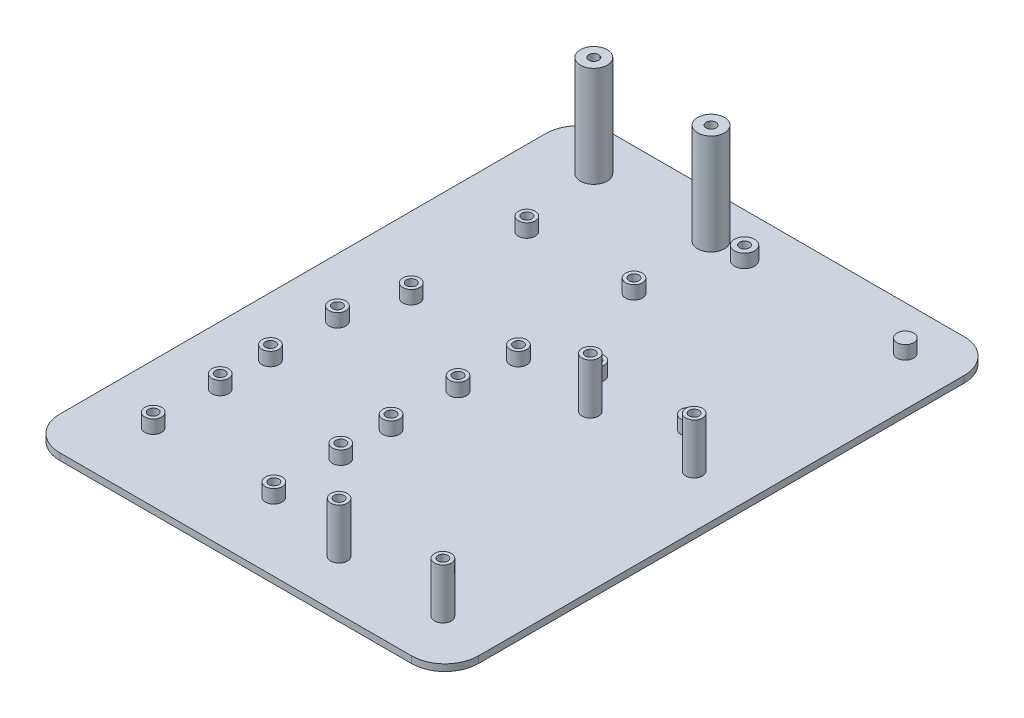
from build123d import *

# Parameters (mm, degrees)
SKETCH_1_R         = 2.5
EXTRUDE_1_DEPTH    = 4
SKETCH_1_R_2       = 3
EXTRUDE_1_2_DEPTH  = 4
EXTRUDE_1_3_DEPTH  = 4
EXTRUDE_1_4_DEPTH  = 4
EXTRUDE_1_5_DEPTH  = 4
EXTRUDE_1_6_DEPTH  = 4
EXTRUDE_1_7_DEPTH  = 4
EXTRUDE_1_8_DEPTH  = 4
EXTRUDE_1_9_DEPTH  = 4
EXTRUDE_1_10_DEPTH = 4
EXTRUDE_1_11_DEPTH = 4
EXTRUDE_1_12_DEPTH = 4
EXTRUDE_1_13_DEPTH = 4
EXTRUDE_1_14_DEPTH = 4
EXTRUDE_1_15_DEPTH = 4
EXTRUDE_1_16_DEPTH = 4
SKETCH_1_3_R       = 2.5
EXTRUDE_2_DEPTH    = 15
EXTRUDE_2_2_DEPTH  = 15
EXTRUDE_2_3_DEPTH  = 15
EXTRUDE_2_4_DEPTH  = 15
SKETCH_1_4_R       = 4
EXTRUDE_3_DEPTH    = 30
EXTRUDE_3_2_DEPTH  = 30
SKETCH_2_W         = 125
SKETCH_2_H         = 165
EXTRUDE_4_DEPTH    = 2
FILLET_1_R         = 10
SKETCH_9_W         = 1.475
SKETCH_9_H         = 30
MM_3_AT_2_COUNT    = 2
MM_3_AT_2_PITCH    = 56.007567425
MM_3_AT_3_COUNT    = 2
MM_3_AT_3_PITCH    = 72.159569674
MM_3_AT_4_COUNT    = 2
MM_3_AT_4_PITCH    = 52.22731905
MM_3_AT_5_COUNT    = 2
MM_3_AT_5_PITCH    = 37.325726715
MM_3_AT_6_COUNT    = 2
MM_3_AT_6_PITCH    = 17.717201651
MM_3_AT_7_COUNT    = 2
MM_3_AT_7_PITCH    = 34.5
MM_3_AT_8_COUNT    = 2
MM_3_AT_8_PITCH    = 59.709714453
MM_3_AT_9_COUNT    = 2
MM_3_AT_9_PITCH    = 66.635200908
MM_3_AT_10_COUNT   = 2
MM_3_AT_10_PITCH   = 71.695536821
MM_3_AT_11_COUNT   = 2
MM_3_AT_11_PITCH   = 75.871602066
MM_3_AT_12_COUNT   = 2
MM_3_AT_12_PITCH   = 86.987675624
MM_3_AT_13_COUNT   = 2
MM_3_AT_13_PITCH   = 116.476846242
MM_3_AT_14_COUNT   = 2
MM_3_AT_14_PITCH   = 95.586858976
MM_3_AT_15_COUNT   = 2
MM_3_AT_15_PITCH   = 78.355146818
MM_3_AT_16_COUNT   = 2
MM_3_AT_16_PITCH   = 60.49973878
MM_3_AT_17_COUNT   = 2
MM_3_AT_17_PITCH   = 48.22587907
MM_3_AT_18_COUNT   = 2
MM_3_AT_18_PITCH   = 35.304741489
MM_3_AT_19_COUNT   = 2
MM_3_AT_19_PITCH   = 32
MM_3_AT_20_COUNT   = 2
MM_3_AT_20_PITCH   = 48.187238975


with BuildPart() as part:
    # 草图1 → 凸台-拉伸1 (new body)
    with BuildSketch(Plane(origin=(0, 0, 0), x_dir=(1, 0, 0), z_dir=(0, 1, 0))):
        with Locations((-8, -25)):
            Circle(SKETCH_1_R)
    extrude(amount=EXTRUDE_1_DEPTH)



with BuildPart() as body_2:
    # 草图1 → Extrude 1 2 (new body)
    with BuildSketch(Plane(origin=(0, 0, 0), x_dir=(1, 0, 0), z_dir=(0, 1, 0))):
        Circle(SKETCH_1_R_2)
    extrude(amount=EXTRUDE_1_2_DEPTH)


with BuildPart() as body_3:
    # 草图1 → Extrude 1 3 (new body)
    with BuildSketch(Plane(origin=(0, 0, 0), x_dir=(1, 0, 0), z_dir=(0, 1, 0))):
        with Locations((-9.048256427, -96.482766011)):
            Circle(SKETCH_1_R)
    extrude(amount=EXTRUDE_1_3_DEPTH)


with BuildPart() as body_4:
    # 草图1 → Extrude 1 4 (new body)
    with BuildSketch(Plane(origin=(0, 0, 0), x_dir=(1, 0, 0), z_dir=(0, 1, 0))):
        with Locations((-45.048256427, -96.482766011)):
            Circle(SKETCH_1_R)
    extrude(amount=EXTRUDE_1_4_DEPTH)


with BuildPart() as body_5:
    # 草图1 → Extrude 1 5 (new body)
    with BuildSketch(Plane(origin=(0, 0, 0), x_dir=(1, 0, 0), z_dir=(0, 1, 0))):
        with Locations((-45.048256427, -76.482766011)):
            Circle(SKETCH_1_R)
    extrude(amount=EXTRUDE_1_5_DEPTH)


with BuildPart() as body_6:
    # 草图1 → Extrude 1 6 (new body)
    with BuildSketch(Plane(origin=(0, 0, 0), x_dir=(1, 0, 0), z_dir=(0, 1, 0))):
        with Locations((-9.048256427, -76.482766011)):
            Circle(SKETCH_1_R)
    extrude(amount=EXTRUDE_1_6_DEPTH)


with BuildPart() as body_7:
    # 草图1 → Extrude 1 7 (new body)
    with BuildSketch(Plane(origin=(0, 0, 0), x_dir=(1, 0, 0), z_dir=(0, 1, 0))):
        with Locations((-45.048256427, -131.482766011)):
            Circle(SKETCH_1_R)
    extrude(amount=EXTRUDE_1_7_DEPTH)


with BuildPart() as body_8:
    # 草图1 → Extrude 1 8 (new body)
    with BuildSketch(Plane(origin=(0, 0, 0), x_dir=(1, 0, 0), z_dir=(0, 1, 0))):
        with Locations((-45.048256427, -111.482766011)):
            Circle(SKETCH_1_R)
    extrude(amount=EXTRUDE_1_8_DEPTH)


with BuildPart() as body_9:
    # 草图1 → Extrude 1 9 (new body)
    with BuildSketch(Plane(origin=(0, 0, 0), x_dir=(1, 0, 0), z_dir=(0, 1, 0))):
        with Locations((-9.048256427, -111.482766011)):
            Circle(SKETCH_1_R)
    extrude(amount=EXTRUDE_1_9_DEPTH)


with BuildPart() as body_10:
    # 草图1 → Extrude 1 10 (new body)
    with BuildSketch(Plane(origin=(0, 0, 0), x_dir=(1, 0, 0), z_dir=(0, 1, 0))):
        with Locations((-40, -59.5)):
            Circle(SKETCH_1_R)
    extrude(amount=EXTRUDE_1_10_DEPTH)


with BuildPart() as body_11:
    # 草图1 → Extrude 1 11 (new body)
    with BuildSketch(Plane(origin=(0, 0, 0), x_dir=(1, 0, 0), z_dir=(0, 1, 0))):
        with Locations((-8, -59.5)):
            Circle(SKETCH_1_R)
    extrude(amount=EXTRUDE_1_11_DEPTH)


with BuildPart() as body_12:
    # 草图1 → Extrude 1 12 (new body)
    with BuildSketch(Plane(origin=(0, 0, 0), x_dir=(1, 0, 0), z_dir=(0, 1, 0))):
        with Locations((48, 0)):
            Circle(SKETCH_1_R)
    extrude(amount=EXTRUDE_1_12_DEPTH)


with BuildPart() as body_13:
    # 草图1 → Extrude 1 13 (new body)
    with BuildSketch(Plane(origin=(0, 0, 0), x_dir=(1, 0, 0), z_dir=(0, 1, 0))):
        with Locations((-9.048256427, -131.482766011)):
            Circle(SKETCH_1_R)
    extrude(amount=EXTRUDE_1_13_DEPTH)


with BuildPart() as body_14:
    # 草图1 → Extrude 1 14 (new body)
    with BuildSketch(Plane(origin=(0, 0, 0), x_dir=(1, 0, 0), z_dir=(0, 1, 0))):
        with Locations((7.6, -52)):
            Circle(SKETCH_1_R)
    extrude(amount=EXTRUDE_1_14_DEPTH)


with BuildPart() as body_15:
    # 草图1 → Extrude 1 15 (new body)
    with BuildSketch(Plane(origin=(0, 0, 0), x_dir=(1, 0, 0), z_dir=(0, 1, 0))):
        with Locations((35.5, -52)):
            Circle(SKETCH_1_R)
    extrude(amount=EXTRUDE_1_15_DEPTH)


with BuildPart() as body_16:
    # 草图1 → Extrude 1 16 (new body)
    with BuildSketch(Plane(origin=(0, 0, 0), x_dir=(1, 0, 0), z_dir=(0, 1, 0))):
        with Locations((-40, -25)):
            Circle(SKETCH_1_R)
    extrude(amount=EXTRUDE_1_16_DEPTH)


with BuildPart() as body_17:
    # 草图1<3> → 凸台-拉伸2 (new body)
    with BuildSketch(Plane(origin=(0, 0, 0), x_dir=(1, 0, 0), z_dir=(0, 1, 0))):
        with Locations((15.951743573, -137)):
            Circle(SKETCH_1_3_R)
    extrude(amount=EXTRUDE_2_DEPTH)


with BuildPart() as body_18:
    # 草图1<3> → Extrude 2 2 (new body)
    with BuildSketch(Plane(origin=(0, 0, 0), x_dir=(1, 0, 0), z_dir=(0, 1, 0))):
        with Locations((46.951743573, -137)):
            Circle(SKETCH_1_3_R)
    extrude(amount=EXTRUDE_2_2_DEPTH)


with BuildPart() as body_19:
    # 草图1<3> → Extrude 2 3 (new body)
    with BuildSketch(Plane(origin=(0, 0, 0), x_dir=(1, 0, 0), z_dir=(0, 1, 0))):
        with Locations((46.951743573, -62)):
            Circle(SKETCH_1_3_R)
    extrude(amount=EXTRUDE_2_3_DEPTH)


with BuildPart() as body_20:
    # 草图1<3> → Extrude 2 4 (new body)
    with BuildSketch(Plane(origin=(0, 0, 0), x_dir=(1, 0, 0), z_dir=(0, 1, 0))):
        with Locations((15.951743573, -62)):
            Circle(SKETCH_1_3_R)
    extrude(amount=EXTRUDE_2_4_DEPTH)


with BuildPart() as body_21:
    # 草图1<4> → 凸台-拉伸3 (new body)
    with BuildSketch(Plane(origin=(0, 0, 0), x_dir=(1, 0, 0), z_dir=(0, 1, 0))):
        with Locations((-45, 0)):
            Circle(SKETCH_1_4_R)
    extrude(amount=EXTRUDE_3_DEPTH)


with BuildPart() as body_22:
    # 草图1<4> → Extrude 3 2 (new body)
    with BuildSketch(Plane(origin=(0, 0, 0), x_dir=(1, 0, 0), z_dir=(0, 1, 0))):
        with Locations((-10, 0)):
            Circle(SKETCH_1_4_R)
    extrude(amount=EXTRUDE_3_2_DEPTH)


with BuildPart() as part_1:
    add(part.part)

    add(body_2.part)  # 凸台-拉伸4 merges body 2

    add(body_3.part)  # 凸台-拉伸4 merges body 3

    add(body_4.part)  # 凸台-拉伸4 merges body 4

    add(body_5.part)  # 凸台-拉伸4 merges body 5

    add(body_6.part)  # 凸台-拉伸4 merges body 6

    add(body_7.part)  # 凸台-拉伸4 merges body 7

    add(body_8.part)  # 凸台-拉伸4 merges body 8

    add(body_9.part)  # 凸台-拉伸4 merges body 9

    add(body_10.part)  # 凸台-拉伸4 merges body 10

    add(body_11.part)  # 凸台-拉伸4 merges body 11

    add(body_12.part)  # 凸台-拉伸4 merges body 12

    add(body_13.part)  # 凸台-拉伸4 merges body 13

    add(body_14.part)  # 凸台-拉伸4 merges body 14

    add(body_15.part)  # 凸台-拉伸4 merges body 15

    add(body_16.part)  # 凸台-拉伸4 merges body 16

    add(body_17.part)  # 凸台-拉伸4 merges body 17

    add(body_18.part)  # 凸台-拉伸4 merges body 18

    add(body_19.part)  # 凸台-拉伸4 merges body 19

    add(body_20.part)  # 凸台-拉伸4 merges body 20

    add(body_21.part)  # 凸台-拉伸4 merges body 21

    add(body_22.part)  # 凸台-拉伸4 merges body 22
    # 草图2 → 凸台-拉伸4 (add)
    with BuildSketch(Plane(origin=(0, 0, 0), x_dir=(1, 0, 0), z_dir=(0, 1, 0))):
        with Locations((0, -69.425835086)):
            Rectangle(SKETCH_2_W, SKETCH_2_H)
    extrude(amount=-EXTRUDE_4_DEPTH)

    # 圆角1
    fillet_1_edges = [part_1.edges().sort_by_distance(p)[0] for p in [
        (62.5, -1, -13.074164914),
        (62.5, -1, 151.925835086),
        (-62.5, -1, 151.925835086),
        (-62.5, -1, -13.074164914),
    ]]
    fillet(fillet_1_edges, radius=FILLET_1_R)

    # 草图9 → mm _3 (revolve, cut)
    with BuildSketch(Plane(origin=(-40, 0, 59.5), x_dir=(0, 0, -1), z_dir=(1, 0, 0))):
        with Locations((0.7375, 15)):
            Rectangle(SKETCH_9_W, SKETCH_9_H)
    mm_3 = revolve(axis=Axis((-40, -6.35, 59.5), (0, 1, 0)), mode=Mode.SUBTRACT)

    # mm _3 at 2: mm _3 ×2
    with Locations(*[Vector(0.99900328, 0, 0.044636825) * (i * MM_3_AT_2_PITCH) for i in range(1, MM_3_AT_2_COUNT)]):
        add(mm_3, mode=Mode.SUBTRACT)

    # mm _3 at 3: mm _3 ×2
    with Locations(*[Vector(-0.069959625, 0, 0.997549824) * (i * MM_3_AT_3_PITCH) for i in range(1, MM_3_AT_3_COUNT)]):
        add(mm_3, mode=Mode.SUBTRACT)

    # mm _3 at 4: mm _3 ×2
    with Locations(*[Vector(-0.096659306, 0, 0.995317526) * (i * MM_3_AT_4_PITCH) for i in range(1, MM_3_AT_4_COUNT)]):
        add(mm_3, mode=Mode.SUBTRACT)

    # mm _3 at 5: mm _3 ×2
    with Locations(*[Vector(-0.135248711, 0, 0.99081168) * (i * MM_3_AT_5_PITCH) for i in range(1, MM_3_AT_5_COUNT)]):
        add(mm_3, mode=Mode.SUBTRACT)

    # mm _3 at 6: mm _3 ×2
    with Locations(*[Vector(-0.284935315, 0, 0.958546747) * (i * MM_3_AT_6_PITCH) for i in range(1, MM_3_AT_6_COUNT)]):
        add(mm_3, mode=Mode.SUBTRACT)

    # mm _3 at 7: mm _3 ×2
    with Locations(*[(0, 0, -i * MM_3_AT_7_PITCH) for i in range(1, MM_3_AT_7_COUNT)]):
        add(mm_3, mode=Mode.SUBTRACT)

    # mm _3 at 8: mm _3 ×2
    with Locations(*[Vector(-0.083738468, 0, -0.996487767) * (i * MM_3_AT_8_PITCH) for i in range(1, MM_3_AT_8_COUNT)]):
        add(mm_3, mode=Mode.SUBTRACT)

    # mm _3 at 9: mm _3 ×2
    with Locations(*[Vector(0.450212494, 0, -0.892921447) * (i * MM_3_AT_9_PITCH) for i in range(1, MM_3_AT_9_COUNT)]):
        add(mm_3, mode=Mode.SUBTRACT)

    # mm _3 at 10: mm _3 ×2
    with Locations(*[Vector(0.557914785, 0, -0.829898242) * (i * MM_3_AT_10_PITCH) for i in range(1, MM_3_AT_10_COUNT)]):
        add(mm_3, mode=Mode.SUBTRACT)

    # mm _3 at 11: mm _3 ×2
    with Locations(*[Vector(0.995102225, 0, -0.098851214) * (i * MM_3_AT_11_PITCH) for i in range(1, MM_3_AT_11_COUNT)]):
        add(mm_3, mode=Mode.SUBTRACT)

    # mm _3 at 12: mm _3 ×2
    with Locations(*[Vector(0.999586929, 0, 0.028739703) * (i * MM_3_AT_12_PITCH) for i in range(1, MM_3_AT_12_COUNT)]):
        add(mm_3, mode=Mode.SUBTRACT)

    # mm _3 at 13: mm _3 ×2
    with Locations(*[Vector(0.746515264, 0, 0.66536829) * (i * MM_3_AT_13_PITCH) for i in range(1, MM_3_AT_13_COUNT)]):
        add(mm_3, mode=Mode.SUBTRACT)

    # mm _3 at 14: mm _3 ×2
    with Locations(*[Vector(0.585349745, 0, 0.810780905) * (i * MM_3_AT_14_PITCH) for i in range(1, MM_3_AT_14_COUNT)]):
        add(mm_3, mode=Mode.SUBTRACT)

    # mm _3 at 15: mm _3 ×2
    with Locations(*[Vector(0.395018641, 0, 0.918673105) * (i * MM_3_AT_15_PITCH) for i in range(1, MM_3_AT_15_COUNT)]):
        add(mm_3, mode=Mode.SUBTRACT)

    # mm _3 at 16: mm _3 ×2
    with Locations(*[Vector(0.511601276, 0, 0.859222983) * (i * MM_3_AT_16_PITCH) for i in range(1, MM_3_AT_16_COUNT)]):
        add(mm_3, mode=Mode.SUBTRACT)

    # mm _3 at 17: mm _3 ×2
    with Locations(*[Vector(0.641807763, 0, 0.766865565) * (i * MM_3_AT_17_PITCH) for i in range(1, MM_3_AT_17_COUNT)]):
        add(mm_3, mode=Mode.SUBTRACT)

    # mm _3 at 18: mm _3 ×2
    with Locations(*[Vector(0.876702173, 0, 0.481033575) * (i * MM_3_AT_18_PITCH) for i in range(1, MM_3_AT_18_COUNT)]):
        add(mm_3, mode=Mode.SUBTRACT)

    # mm _3 at 19: mm _3 ×2
    with Locations(*[(i * MM_3_AT_19_PITCH, 0, 0) for i in range(1, MM_3_AT_19_COUNT)]):
        add(mm_3, mode=Mode.SUBTRACT)

    # mm _3 at 20: mm _3 ×2
    with Locations(*[Vector(0.987813392, 0, -0.155642866) * (i * MM_3_AT_20_PITCH) for i in range(1, MM_3_AT_20_COUNT)]):
        add(mm_3, mode=Mode.SUBTRACT)

    # 草图10 → mm _3 2 (revolve, cut)
    with BuildSketch(Plane(origin=(-8, 0, 25), x_dir=(0, 0, -1), z_dir=(1, 0, 0))):
        Polygon((0, 0), (0, 30), (1.475, 30), (1.475, 0.05), (1.525, 0), align=None)
    revolve(axis=Axis((-8, -6.35, 25), (0, 1, 0)), mode=Mode.SUBTRACT)


solid = part_1.part
